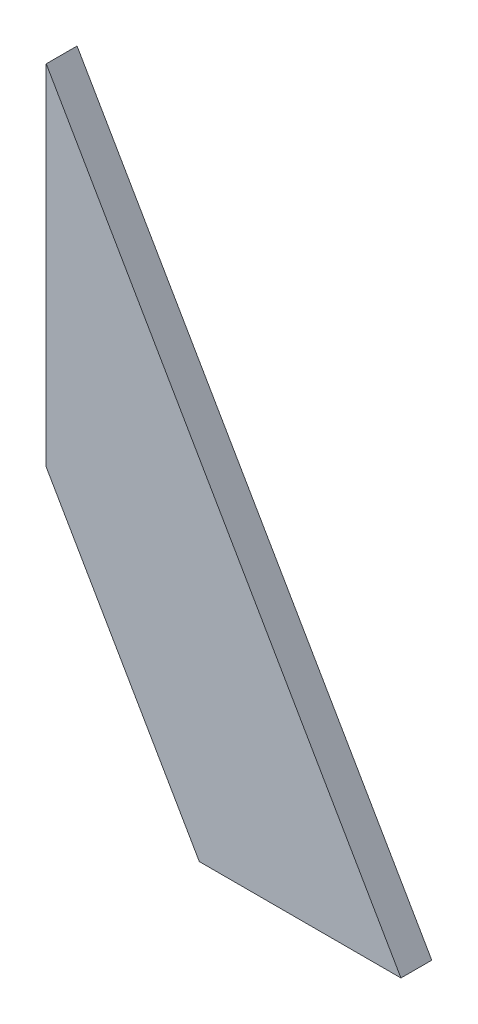
from build123d import *

# Parameters (mm, degrees)
BOSS_EXTRUDE1_DEPTH = 3


with BuildPart() as part:
    # Sketch1 → Boss-Extrude1 (new body)
    with BuildSketch(Plane.XY):
        Polygon((-816.187231936, 260.397454325), (-816.187231936, 226.400083913), (-801.286440787, 200.591156571), (-781.658049828, 200.591156571), align=None)
    extrude(amount=BOSS_EXTRUDE1_DEPTH)


solid = part.part
